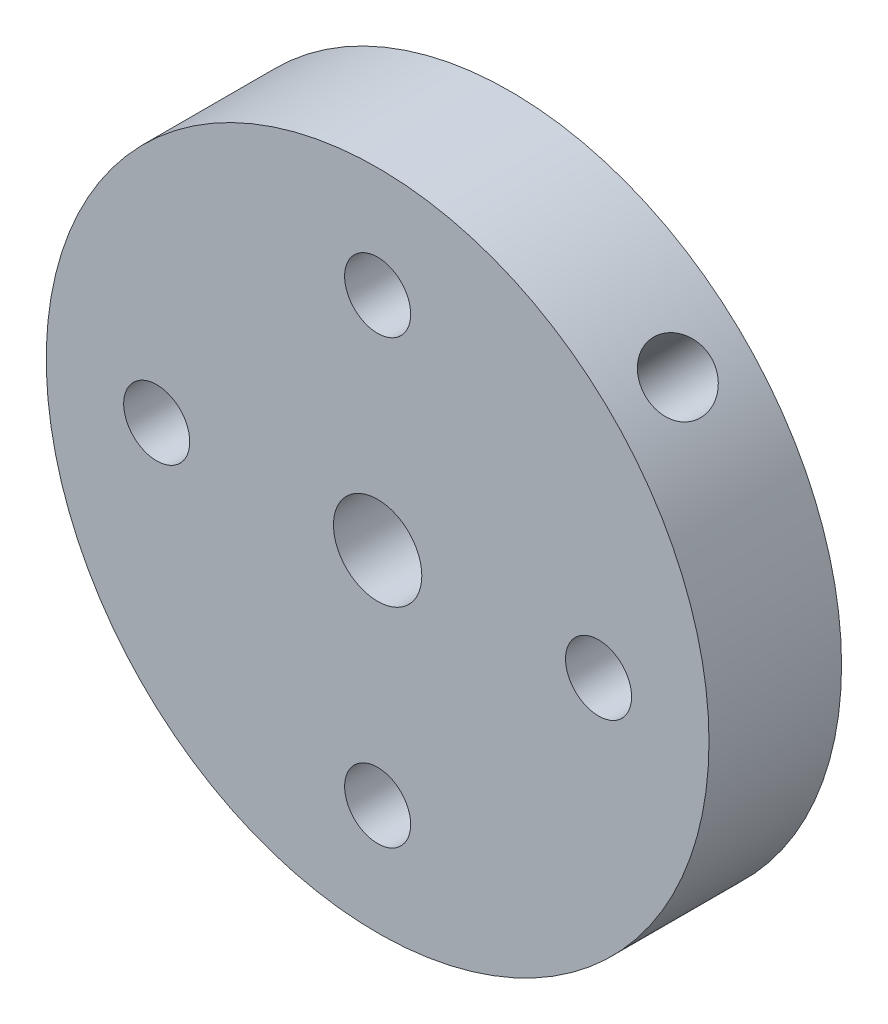
from build123d import *

# Parameters (mm, degrees)
SKETCH1_R                  = 19.05
BOSS_EXTRUDE1_DEPTH        = 7.62
SKETCH2_R                  = 2.54
CUT_EXTRUDE1_DEPTH         = 8.62
F_10_24_TAPPED_HOLE1_D     = 3.7973
CIRPATTERN1_COUNT          = 4
F_10_24_TAPPED_HOLE4_D     = 3.7973
F_10_24_TAPPED_HOLE4_DEPTH = 20.0279
F_10_24_TAPPED_HOLE4_TIP   = 1.140824014


with BuildPart() as part:
    # Sketch1 → Boss-Extrude1 (new body)
    with BuildSketch(Plane.XY):
        Circle(SKETCH1_R)
    extrude(amount=BOSS_EXTRUDE1_DEPTH)

    # Sketch2 → Cut-Extrude1 (cut, through all)
    with BuildSketch(Plane.XY.offset(7.62)):
        Circle(SKETCH2_R)
    extrude(amount=-CUT_EXTRUDE1_DEPTH, mode=Mode.SUBTRACT)

    # #10-24 Tapped Hole1 (through all)
    with Locations(Plane.XY.offset(7.62)):
        with Locations((0, 12.7)):
            f_10_24_tapped_hole1 = Hole(F_10_24_TAPPED_HOLE1_D / 2)

    # CirPattern1: #10-24 Tapped Hole1 ×4 about axis
    cirpattern1_axis = Axis((0, 0, 0), (0, 0, 1))
    for i in range(1, CIRPATTERN1_COUNT):
        add(f_10_24_tapped_hole1.rotate(cirpattern1_axis, i * 360 / CIRPATTERN1_COUNT), mode=Mode.SUBTRACT)

    # #10-24 Tapped Hole4
    with Locations(Plane(origin=(13.470384182, 13.470384182, 7.62), x_dir=(-0.707106781, 0.707106781, 0), z_dir=(0.707106781, 0.707106781, 0))):
        with Locations((0, -3.81)):
            Hole(F_10_24_TAPPED_HOLE4_D / 2, depth=F_10_24_TAPPED_HOLE4_DEPTH)
            with Locations((0, 0, -(F_10_24_TAPPED_HOLE4_DEPTH + F_10_24_TAPPED_HOLE4_TIP / 2))):  # 118° drill point
                Cone(0, F_10_24_TAPPED_HOLE4_D / 2, F_10_24_TAPPED_HOLE4_TIP, mode=Mode.SUBTRACT)


solid = part.part
